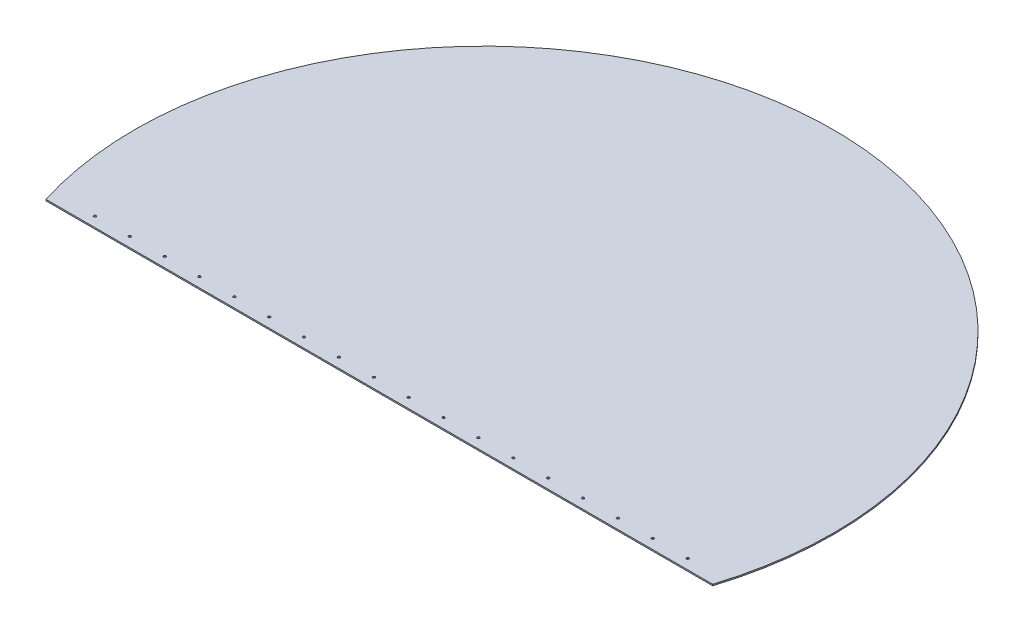
from build123d import *

# Parameters (mm, degrees)
BOSS_EXTRUDE1_DEPTH = 1.98374
SKETCH2_R           = 1.778
CUT_EXTRUDE1_DEPTH  = 3.175
LPATTERN1_COUNT     = 18
LPATTERN1_PITCH     = 50.8


with BuildPart() as part:
    # Sketch1 → Boss-Extrude1 (new body)
    with BuildSketch(Plane(origin=(0, 0, 0), x_dir=(1, 0, 0), z_dir=(0, 1, 0))):
        with BuildLine():
            Line((-485.639445359, -152.4), (485.639445359, -152.4))
            ThreePointArc((485.639445359, -152.4), (0, 508.9906), (-485.639445359, -152.4))
        make_face()
    extrude(amount=BOSS_EXTRUDE1_DEPTH)

    # Sketch2 → Cut-Extrude1 (cut)
    with BuildSketch(Plane(origin=(0, 1.98374, 0), x_dir=(1, 0, 0), z_dir=(0, 1, 0))):
        with Locations(Location((434.839445359, -138.1125, 0), (0, 0, 270))):  # turned: the seam where the file's is
            Circle(SKETCH2_R)
    cut_extrude1 = extrude(amount=-CUT_EXTRUDE1_DEPTH, mode=Mode.SUBTRACT)

    # LPattern1: Cut-Extrude1 ×18
    with Locations(*[(-i * LPATTERN1_PITCH, 0, 0) for i in range(1, LPATTERN1_COUNT)]):
        add(cut_extrude1, mode=Mode.SUBTRACT)


solid = part.part
